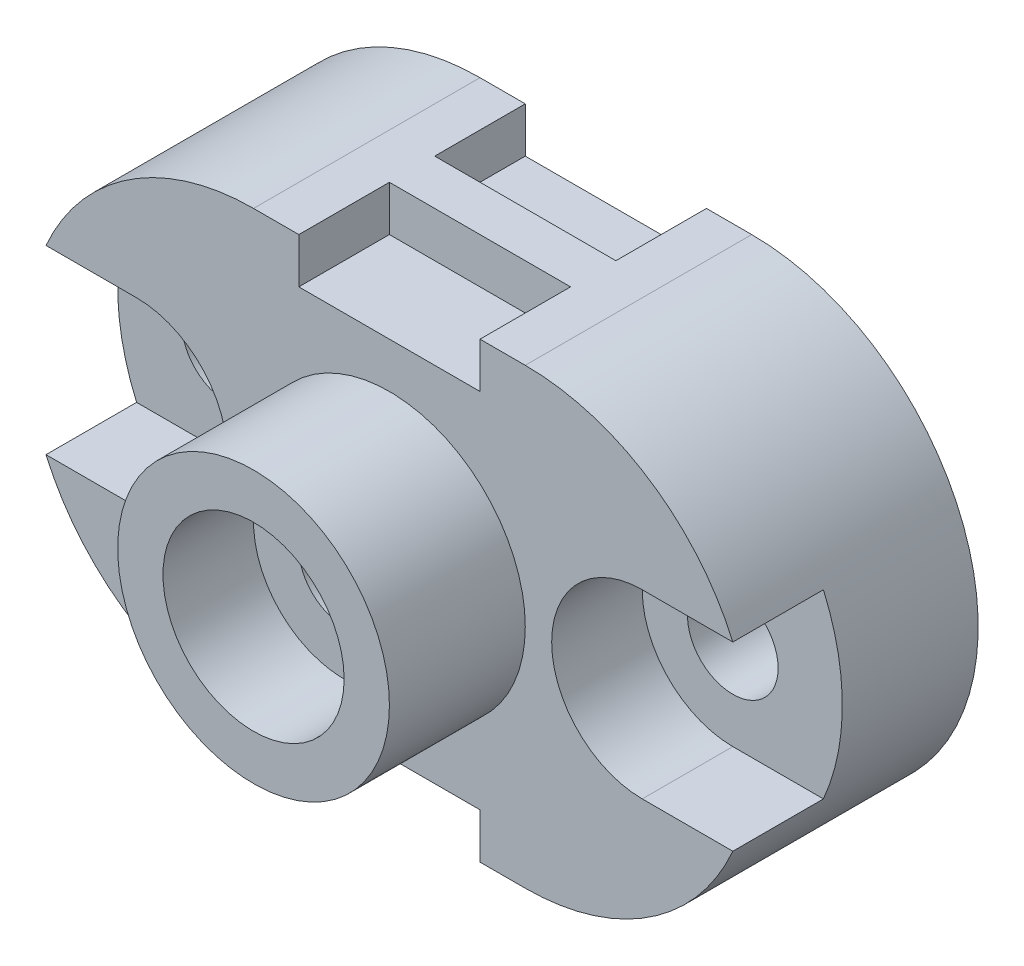
from build123d import *

# Parameters (mm, degrees)
BOSS_EXTRUDE2_DEPTH = 25
SKETCH2_W           = 20
SKETCH2_H           = 5
CUT_EXTRUDE2_DEPTH  = 10
SKETCH3_W           = 20
SKETCH3_H           = 5
CUT_EXTRUDE3_DEPTH  = 10
SKETCH4_R           = 15
BOSS_EXTRUDE3_DEPTH = 15
SKETCH5_R           = 10
CUT_EXTRUDE4_DEPTH  = 10
SKETCH6_R           = 5
CUT_EXTRUDE9_DEPTH  = 300
CUT_EXTRUDE10_DEPTH = 10
SKETCH9_R           = 5
CUT_EXTRUDE11_DEPTH = 70


with BuildPart() as part:
    # Sketch1 → Boss-Extrude2 (new body)
    with BuildSketch(Plane.XY):
        with BuildLine():
            Line((-30, 0), (0, 0))
            ThreePointArc((0, 0), (25, -25), (0, -50))
            Line((0, -50), (-30, -50))
            ThreePointArc((-30, -50), (-55, -25), (-30, 0))
        make_face()
    extrude(amount=BOSS_EXTRUDE2_DEPTH)

    # Sketch2 → Cut-Extrude2 (cut)
    with BuildSketch(Plane.XY.offset(25)):
        with Locations((-15, -2.5)):
            Rectangle(SKETCH2_W, SKETCH2_H)
        with Locations((-15, -47.5)):
            Rectangle(SKETCH2_W, SKETCH2_H)
    extrude(amount=-CUT_EXTRUDE2_DEPTH, mode=Mode.SUBTRACT)

    # Sketch3 → Cut-Extrude3 (cut)
    with BuildSketch(Plane(origin=(0, 0, 0), x_dir=(-1, 0, 0), z_dir=(0, 0, -1))):
        with Locations((15, -2.5)):
            Rectangle(SKETCH3_W, SKETCH3_H)
        with Locations((15, -47.5)):
            Rectangle(SKETCH3_W, SKETCH3_H)
    extrude(amount=-CUT_EXTRUDE3_DEPTH, mode=Mode.SUBTRACT)

    # Sketch4 → Boss-Extrude3 (add)
    with BuildSketch(Plane.XY.offset(25)):
        with Locations((-15, -25)):
            Circle(SKETCH4_R)
    extrude(amount=BOSS_EXTRUDE3_DEPTH)

    # Sketch5 → Cut-Extrude4 (cut)
    with BuildSketch(Plane.XY.offset(40)):
        with Locations((-15, -25)):
            Circle(SKETCH5_R)
    extrude(amount=-CUT_EXTRUDE4_DEPTH, mode=Mode.SUBTRACT)

    # Sketch6 → Cut-Extrude9 (cut)
    with BuildSketch(Plane.XY.offset(30)):
        with Locations((-15, -25)):
            Circle(SKETCH6_R)
    extrude(amount=-CUT_EXTRUDE9_DEPTH, mode=Mode.SUBTRACT)

    # Sketch8 → Cut-Extrude10 (cut)
    with BuildSketch(Plane.XY.offset(25)):
        with BuildLine():
            Line((22.912878475, -35), (12.912878475, -35))
            ThreePointArc((12.912878475, -35), (2.912878475, -25), (12.912878475, -15))
            Line((12.912878475, -15), (22.912878475, -15))
            ThreePointArc((22.912878475, -15), (25, -25), (22.912878475, -35))
        make_face()
        with BuildLine():
            Line((-52.912878475, -15), (-42.912878475, -15))
            ThreePointArc((-42.912878475, -15), (-32.912878475, -25), (-42.912878475, -35))
            Line((-42.912878475, -35), (-52.912878475, -35))
            ThreePointArc((-52.912878475, -35), (-55, -25), (-52.912878475, -15))
        make_face()
    extrude(amount=-CUT_EXTRUDE10_DEPTH, mode=Mode.SUBTRACT)

    # Sketch9 → Cut-Extrude11 (cut)
    with BuildSketch(Plane.XY.offset(15)):
        with Locations((-42.912878475, -25)):
            Circle(SKETCH9_R)
        with Locations((12.912878475, -25)):
            Circle(SKETCH9_R)
    extrude(amount=-CUT_EXTRUDE11_DEPTH, mode=Mode.SUBTRACT)


solid = part.part
